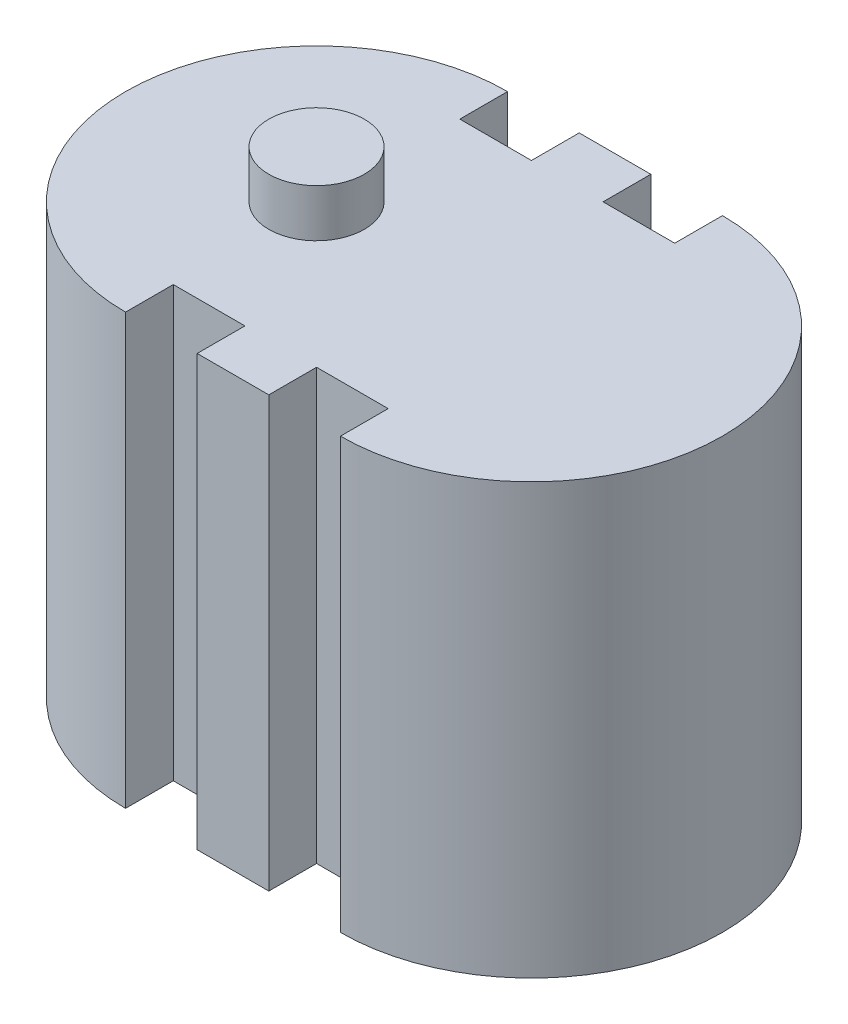
from build123d import *

# Parameters (mm, degrees)
EXTRUDE1_DEPTH = 90
SKETCH2_R      = 10
EXTRUDE2_DEPTH = 10


with BuildPart() as part:
    # Sketch1 → Extrude1 (new body)
    with BuildSketch(Plane(origin=(0, 0, 0), x_dir=(1, 0, 0), z_dir=(0, 1, 0))):
        with BuildLine():
            Line((0, 40), (0, 30))
            Line((0, 30), (15, 30))
            Line((15, 30), (15, 40))
            Line((15, 40), (30, 40))
            Line((30, 40), (30, 30))
            Line((30, 30), (45, 30))
            Line((45, 30), (45, 40))
            ThreePointArc((45, 40), (85, 0), (45, -40))
            Line((45, -40), (45, -30))
            Line((45, -30), (30, -30))
            Line((30, -30), (30, -40))
            Line((30, -40), (15, -40))
            Line((15, -40), (15, -30))
            Line((15, -30), (0, -30))
            Line((0, -30), (0, -40))
            ThreePointArc((0, -40), (-40, 0), (0, 40))
        make_face()
    extrude(amount=EXTRUDE1_DEPTH)

    # Sketch2 → Extrude2 (add)
    with BuildSketch(Plane(origin=(0, 90, 0), x_dir=(-1, 0, 0), z_dir=(0, 1, 0))):
        with Locations(Location((0, 0, 0), (0, 0, 90))):  # turned: the seam where the file's is
            Circle(SKETCH2_R)
    extrude(amount=EXTRUDE2_DEPTH)


solid = part.part
